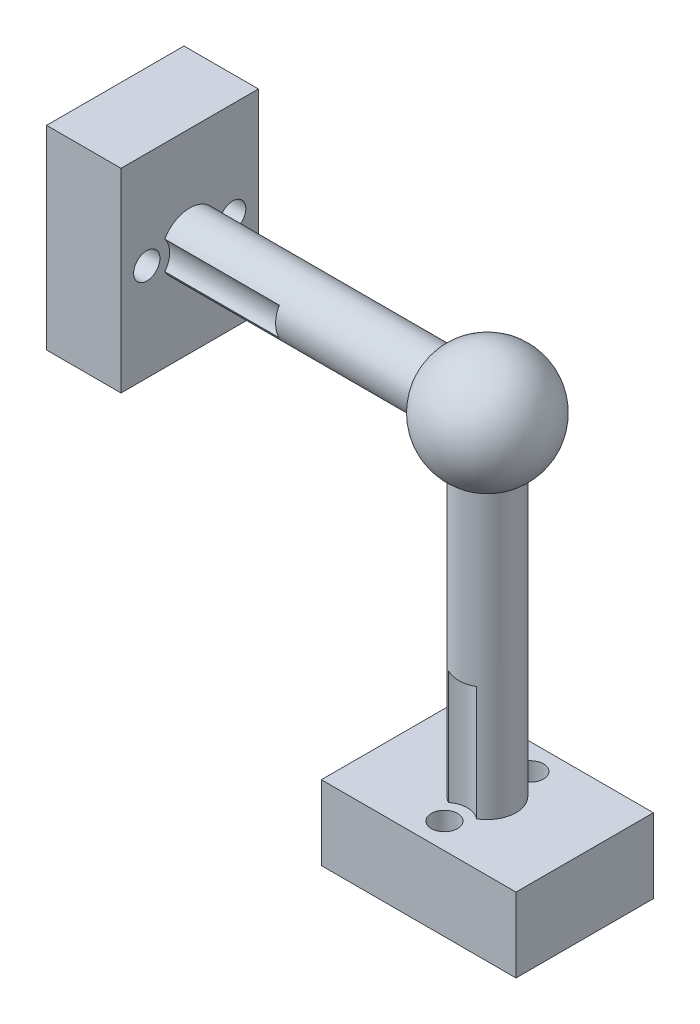
from build123d import *

# Parameters (mm, degrees)
SKETCH_2_R          = 2.5
EXTRUDE_1_DEPTH     = 29
SKETCH_3_R          = 2.5
EXTRUDE_2_DEPTH     = 26
SKETCH_5_W          = 17
SKETCH_5_H          = 12
SKETCH_5_R          = 1.15
EXTRUDE_4_DEPTH     = 6.5
SKETCH_6_R          = 2
CUT_EXTRUDE_1_DEPTH = 10
SKETCH_7_W          = 12
SKETCH_7_H          = 17
SKETCH_7_R          = 1.15
EXTRUDE_5_DEPTH     = 6.5
SKETCH_8_R          = 2
CUT_EXTRUDE_2_DEPTH = 10


with BuildPart() as part:
    # 스케치1 → 회전1 (revolve)
    with BuildSketch(Plane.XY):
        with BuildLine():
            Line((0, -5), (0, 5))
            ThreePointArc((0, 5), (-5, 0), (0, -5))
        make_face()
    revolve(axis=Axis((0, 7.642806544, 0), (0, -1, 0)))

    # 스케치2 → 보스-돌출1 (add)
    with BuildSketch(Plane(origin=(0, 0, 0), x_dir=(1, 0, 0), z_dir=(0, 1, 0))):
        Circle(SKETCH_2_R)
    extrude(amount=-EXTRUDE_1_DEPTH)

    # 스케치3 → 보스-돌출2 (add)
    with BuildSketch(Plane(origin=(0, 0, 0), x_dir=(0, 0, -1), z_dir=(1, 0, 0))):
        Circle(SKETCH_3_R)
    extrude(amount=-EXTRUDE_2_DEPTH)

    # 스케치5 → 보스-돌출4 (add)
    with BuildSketch(Plane(origin=(0, -35.5, 0), x_dir=(-1, 0, 0), z_dir=(0, -1, 0))):
        Rectangle(SKETCH_5_W, SKETCH_5_H)
        with Locations((0, 3.75)):
            Circle(SKETCH_5_R, mode=Mode.SUBTRACT)
        with Locations((0, -3.75)):
            Circle(SKETCH_5_R, mode=Mode.SUBTRACT)
    extrude(amount=-EXTRUDE_4_DEPTH)

    # 스케치6 → 컷-돌출1 (cut)
    with BuildSketch(Plane(origin=(0, -29, 0), x_dir=(1, 0, 0), z_dir=(0, 1, 0))):
        with Locations((0, 3.75)):
            Circle(SKETCH_6_R)
        with Locations((0, -3.75)):
            Circle(SKETCH_6_R)
    extrude(amount=CUT_EXTRUDE_1_DEPTH, mode=Mode.SUBTRACT)

    # 스케치7 → 보스-돌출5 (add)
    with BuildSketch(Plane(origin=(-32.5, 0, 0), x_dir=(0, 0, -1), z_dir=(1, 0, 0))):
        Rectangle(SKETCH_7_W, SKETCH_7_H)
        with Locations((-3.75, 0)):
            Circle(SKETCH_7_R, mode=Mode.SUBTRACT)
        with Locations((3.75, 0)):
            Circle(SKETCH_7_R, mode=Mode.SUBTRACT)
    extrude(amount=EXTRUDE_5_DEPTH)

    # 스케치8 → 컷-돌출2 (cut)
    with BuildSketch(Plane(origin=(-26, 0, 0), x_dir=(0, 0, -1), z_dir=(1, 0, 0))):
        with Locations((-3.75, 0)):
            Circle(SKETCH_8_R)
        with Locations((3.75, 0)):
            Circle(SKETCH_8_R)
    extrude(amount=CUT_EXTRUDE_2_DEPTH, mode=Mode.SUBTRACT)


solid = part.part
